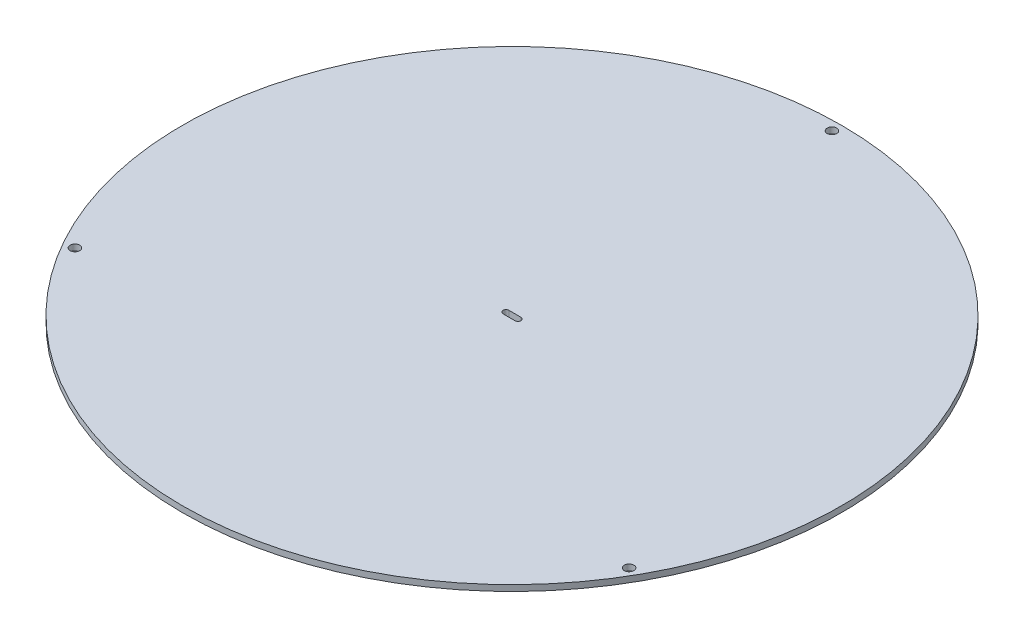
from build123d import *

# Parameters (mm, degrees)
ESQUISSE1_R                  = 110
BOSS_EXTRU_1_DEPTH           = 2
ESQUISSE2_R                  = 1.6
ENL_V_MAT_EXTRU_1_DEPTH      = 3
R_P_TITION_CIRCULAIRE2_COUNT = 3


with BuildPart() as part:
    # Esquisse1 → Boss.-Extru.1 (new body)
    with BuildSketch(Plane(origin=(0, 0, 0), x_dir=(1, 0, 0), z_dir=(0, 1, 0))):
        Circle(ESQUISSE1_R)
        with BuildLine():
            Line((-2, 1), (2, 1))
            ThreePointArc((2, 1), (3, 0), (2, -1))
            Line((2, -1), (-2, -1))
            ThreePointArc((-2, -1), (-3, 0), (-2, 1))
        make_face(mode=Mode.SUBTRACT)
    extrude(amount=BOSS_EXTRU_1_DEPTH)

    # Esquisse2 → Enlèv. mat.-Extru.1 (cut, through all)
    with BuildSketch(Plane(origin=(0, 2, 0), x_dir=(1, 0, 0), z_dir=(0, 1, 0))):
        with Locations((0, 106.8)):
            Circle(ESQUISSE2_R)
    enl_v_mat_extru_1 = extrude(amount=-ENL_V_MAT_EXTRU_1_DEPTH, mode=Mode.SUBTRACT)

    # Répétition circulaire2: Enlèv. mat.-Extru.1 ×3 about axis
    r_p_tition_circulaire2_axis = Axis((0, 0, 0), (0, 1, 0))
    for i in range(1, R_P_TITION_CIRCULAIRE2_COUNT):
        add(enl_v_mat_extru_1.rotate(r_p_tition_circulaire2_axis, i * 360 / R_P_TITION_CIRCULAIRE2_COUNT), mode=Mode.SUBTRACT)


solid = part.part
